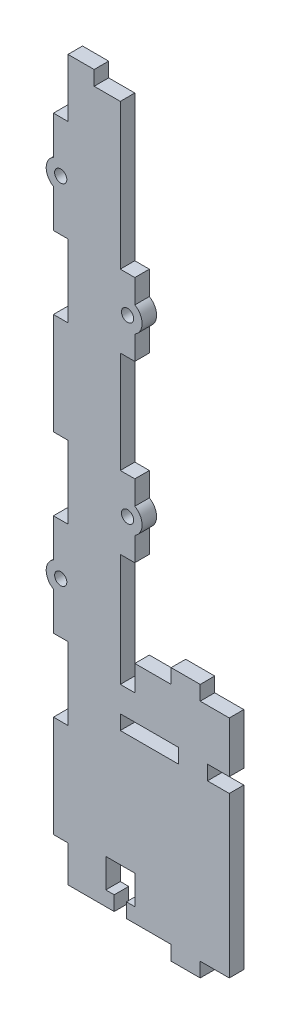
from build123d import *

# Parameters (mm, degrees)
SKETCH1_W            = 18
SKETCH1_H            = 242.5
BOSS_EXTRUDE2_DEPTH  = 5
SKETCH2_W            = 9
SKETCH2_H            = 5
BOSS_EXTRUDE3_DEPTH  = 5
SKETCH3_W            = 5
SKETCH3_H            = 35
BOSS_EXTRUDE4_DEPTH  = 5
SKETCH4_W            = 5
SKETCH4_H            = 25
BOSS_EXTRUDE5_DEPTH  = 5
SKETCH5_W            = 5
SKETCH5_H            = 55
BOSS_EXTRUDE6_DEPTH  = 37.5
SKETCH6_W            = 10
SKETCH6_H            = 5
BOSS_EXTRUDE7_DEPTH  = 5
SKETCH7_W            = 5
SKETCH7_H            = 8.75
BOSS_EXTRUDE8_DEPTH  = 5
SKETCH8_W            = 10
SKETCH8_H            = 5
BOSS_EXTRUDE9_DEPTH  = 5
SKETCH9_W            = 32.5
SKETCH9_H            = 17.5
BOSS_EXTRUDE10_DEPTH = 5
SKETCH10_W           = 10
SKETCH10_H           = 5
BOSS_EXTRUDE11_DEPTH = 5
SKETCH11_R           = 2.1
CUT_EXTRUDE1_DEPTH   = 5
BOSS_EXTRUDE12_DEPTH = 5
SKETCH13_R           = 2.1
CUT_EXTRUDE2_DEPTH   = 5
BOSS_EXTRUDE13_DEPTH = 5
SKETCH15_W           = 4.2
SKETCH15_H           = 5
SKETCH15_W_2         = 10
SKETCH15_H_2         = 10
CUT_EXTRUDE3_DEPTH   = 10


with BuildPart() as part:
    # Sketch1 → Boss-Extrude2 (new body)
    with BuildSketch(Plane.XY):
        with Locations((-9, 121.25)):
            Rectangle(SKETCH1_W, SKETCH1_H)
    extrude(amount=BOSS_EXTRUDE2_DEPTH)

    # Sketch2 → Boss-Extrude3 (add)
    with BuildSketch(Plane(origin=(0, 242.5, 0), x_dir=(1, 0, 0), z_dir=(0, 1, 0))):
        with Locations((-13.5, -2.5)):
            Rectangle(SKETCH2_W, SKETCH2_H)
    extrude(amount=BOSS_EXTRUDE3_DEPTH)

    # Sketch3 → Boss-Extrude4 (add)
    with BuildSketch(Plane(origin=(0, 0, 0), x_dir=(-1, 0, 0), z_dir=(0, 0, -1))):
        with Locations((20.5, 210)):
            Rectangle(SKETCH3_W, SKETCH3_H)
        with Locations((20.5, 150)):
            Rectangle(SKETCH3_W, SKETCH3_H)
        with Locations((20.5, 90)):
            Rectangle(SKETCH3_W, SKETCH3_H)
        with Locations((20.5, 30)):
            Rectangle(SKETCH3_W, SKETCH3_H)
    extrude(amount=-BOSS_EXTRUDE4_DEPTH)

    # Sketch4 → Boss-Extrude5 (add)
    with BuildSketch(Plane.XY.offset(5)):
        with Locations((2.5, 180)):
            Rectangle(SKETCH4_W, SKETCH4_H)
        with Locations((2.5, 120)):
            Rectangle(SKETCH4_W, SKETCH4_H)
    extrude(amount=-BOSS_EXTRUDE5_DEPTH)

    # Sketch5 → Boss-Extrude6 (add)
    with BuildSketch(Plane(origin=(0, 0, 0), x_dir=(0, 0, -1), z_dir=(1, 0, 0))):
        with Locations((-2.5, 27.5)):
            Rectangle(SKETCH5_W, SKETCH5_H)
    extrude(amount=BOSS_EXTRUDE6_DEPTH)

    # Sketch6 → Boss-Extrude7 (add)
    with BuildSketch(Plane.XY.offset(5)):
        with Locations((25, 57.5)):
            Rectangle(SKETCH6_W, SKETCH6_H)
    extrude(amount=-BOSS_EXTRUDE7_DEPTH)

    # Sketch7 → Boss-Extrude8 (add)
    with BuildSketch(Plane.XY.offset(5)):
        with Locations((2.5, 64.375)):
            Rectangle(SKETCH7_W, SKETCH7_H)
    extrude(amount=-BOSS_EXTRUDE8_DEPTH)

    # Sketch8 → Boss-Extrude9 (add)
    with BuildSketch(Plane.XY.offset(5)):
        with Locations((22.5, -2.5)):
            Rectangle(SKETCH8_W, SKETCH8_H)
    extrude(amount=-BOSS_EXTRUDE9_DEPTH)

    # Sketch9 → Boss-Extrude10 (add)
    with BuildSketch(Plane.XY.offset(5)):
        with Locations((21.25, 68.75)):
            Rectangle(SKETCH9_W, SKETCH9_H)
    extrude(amount=-BOSS_EXTRUDE10_DEPTH)

    # Sketch10 → Boss-Extrude11 (add)
    with BuildSketch(Plane.XY.offset(5)):
        with Locations((22.5, 80)):
            Rectangle(SKETCH10_W, SKETCH10_H)
    extrude(amount=-BOSS_EXTRUDE11_DEPTH)

    # Sketch11 → Cut-Extrude1 (cut)
    with BuildSketch(Plane(origin=(0, 0, 0), x_dir=(-1, 0, 0), z_dir=(0, 0, -1))):
        with Locations((-2.5, 180)):
            Circle(SKETCH11_R)
        with Locations((-2.5, 120)):
            Circle(SKETCH11_R)
    extrude(amount=-CUT_EXTRUDE1_DEPTH, mode=Mode.SUBTRACT)

    # Sketch12 → Boss-Extrude12 (add)
    with BuildSketch(Plane(origin=(0, 0, 0), x_dir=(-1, 0, 0), z_dir=(0, 0, -1))):
        with BuildLine():
            Line((-5, 175.669872981), (-5, 184.330127019))
            ThreePointArc((-5, 184.330127019), (-7.5, 180), (-5, 175.669872981))
        make_face()
        with BuildLine():
            Line((-5, 124.330127019), (-5, 115.669872981))
            ThreePointArc((-5, 115.669872981), (-7.5, 120), (-5, 124.330127019))
        make_face()
    extrude(amount=-BOSS_EXTRUDE12_DEPTH)

    # Sketch13 → Cut-Extrude2 (cut)
    with BuildSketch(Plane.XY.offset(5)):
        with Locations((-20.5, 210)):
            Circle(SKETCH13_R)
        with Locations((-20.5, 90)):
            Circle(SKETCH13_R)
    extrude(amount=-CUT_EXTRUDE2_DEPTH, mode=Mode.SUBTRACT)

    # Sketch14 → Boss-Extrude13 (add)
    with BuildSketch(Plane.XY.offset(5)):
        with BuildLine():
            Line((-23, 214.330127019), (-23, 205.669872981))
            ThreePointArc((-23, 205.669872981), (-25.5, 210), (-23, 214.330127019))
        make_face()
        with BuildLine():
            Line((-23, 85.669872981), (-23, 94.330127019))
            ThreePointArc((-23, 94.330127019), (-25.5, 90), (-23, 85.669872981))
        make_face()
    extrude(amount=-BOSS_EXTRUDE13_DEPTH)

    # Sketch15 → Cut-Extrude3 (cut)
    with BuildSketch(Plane.XY.offset(5)):
        with Locations((0, 2.5)):
            Rectangle(SKETCH15_W, SKETCH15_H)
        with Locations((0, 10)):
            Rectangle(SKETCH15_W_2, SKETCH15_H_2)
    extrude(amount=-CUT_EXTRUDE3_DEPTH, mode=Mode.SUBTRACT)


solid = part.part
